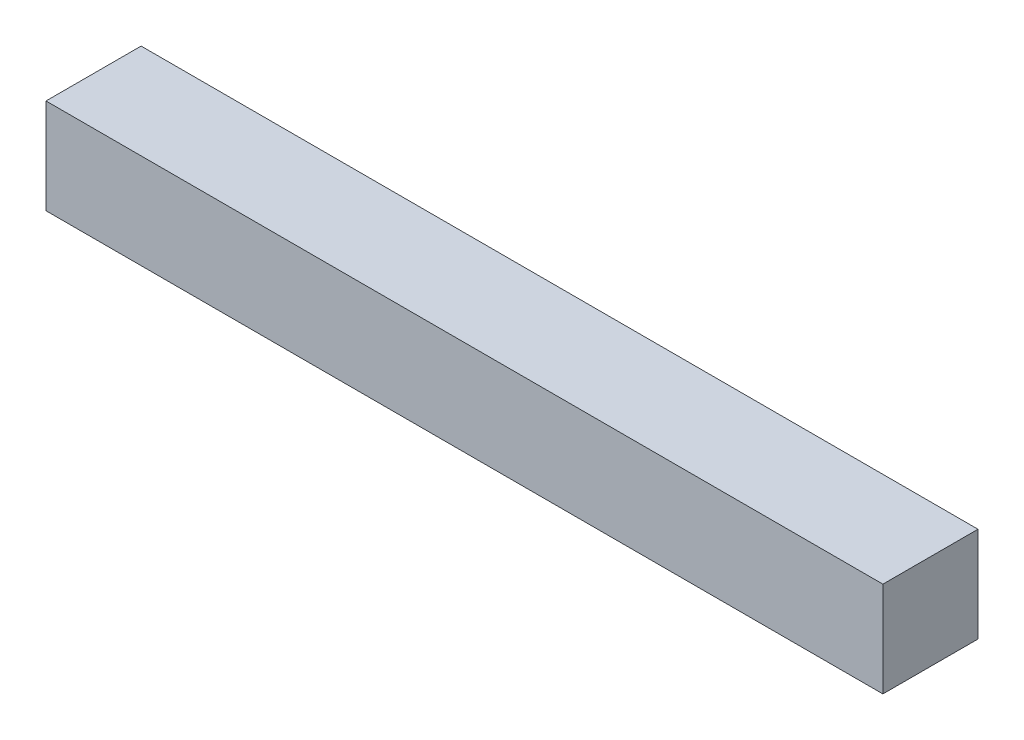
from build123d import *

# Parameters (mm, degrees)
SKETCH1_W           = 440
SKETCH1_H           = 50
BOSS_EXTRUDE1_DEPTH = 50


with BuildPart() as part:
    # Sketch1 → Boss-Extrude1 (new body)
    with BuildSketch(Plane.XY):
        Rectangle(SKETCH1_W, SKETCH1_H)
    extrude(amount=BOSS_EXTRUDE1_DEPTH)


solid = part.part
